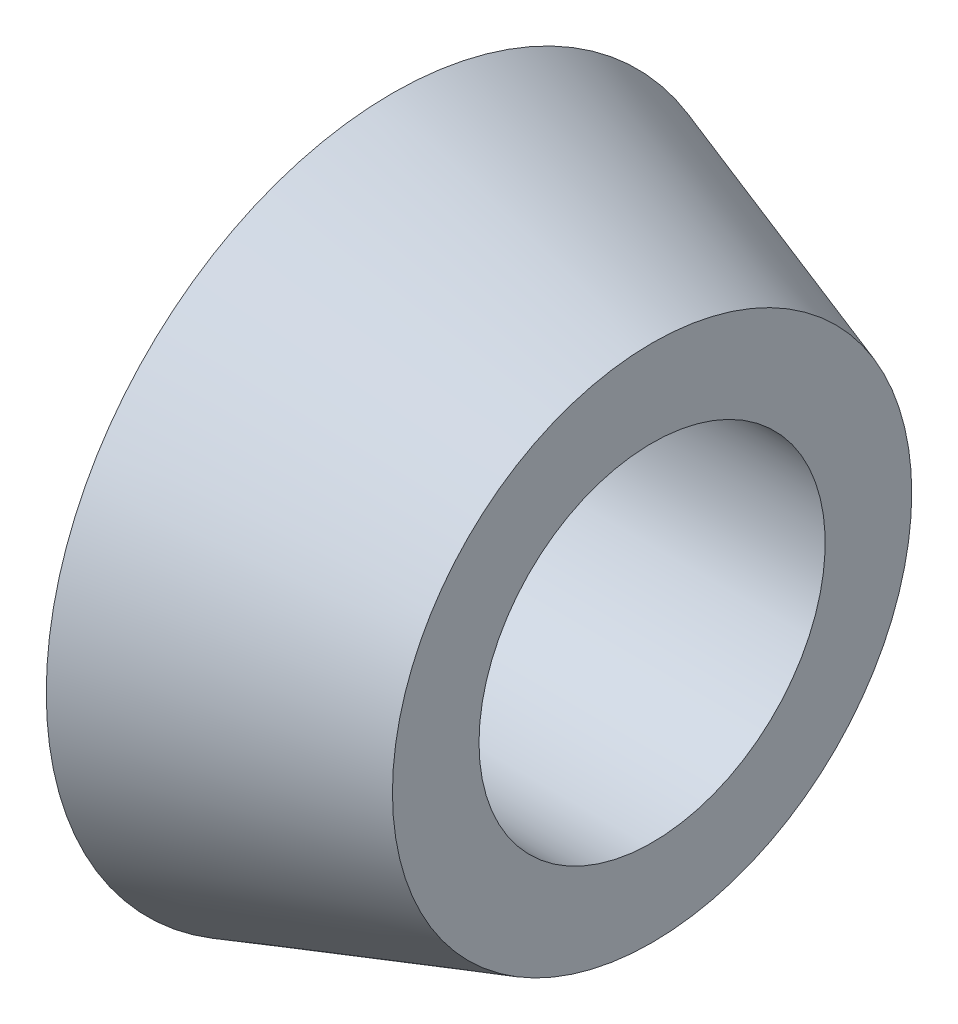
from build123d import *


with BuildPart() as part:
    # Szkic1 → Obrót1 (revolve)
    with BuildSketch(Plane.XY):
        Polygon((0, 3), (4.5, 3), (4.5, 4.5), (0, 6), align=None)
    revolve(axis=Axis((0, 0, 0), (1, 0, 0)))


solid = part.part
